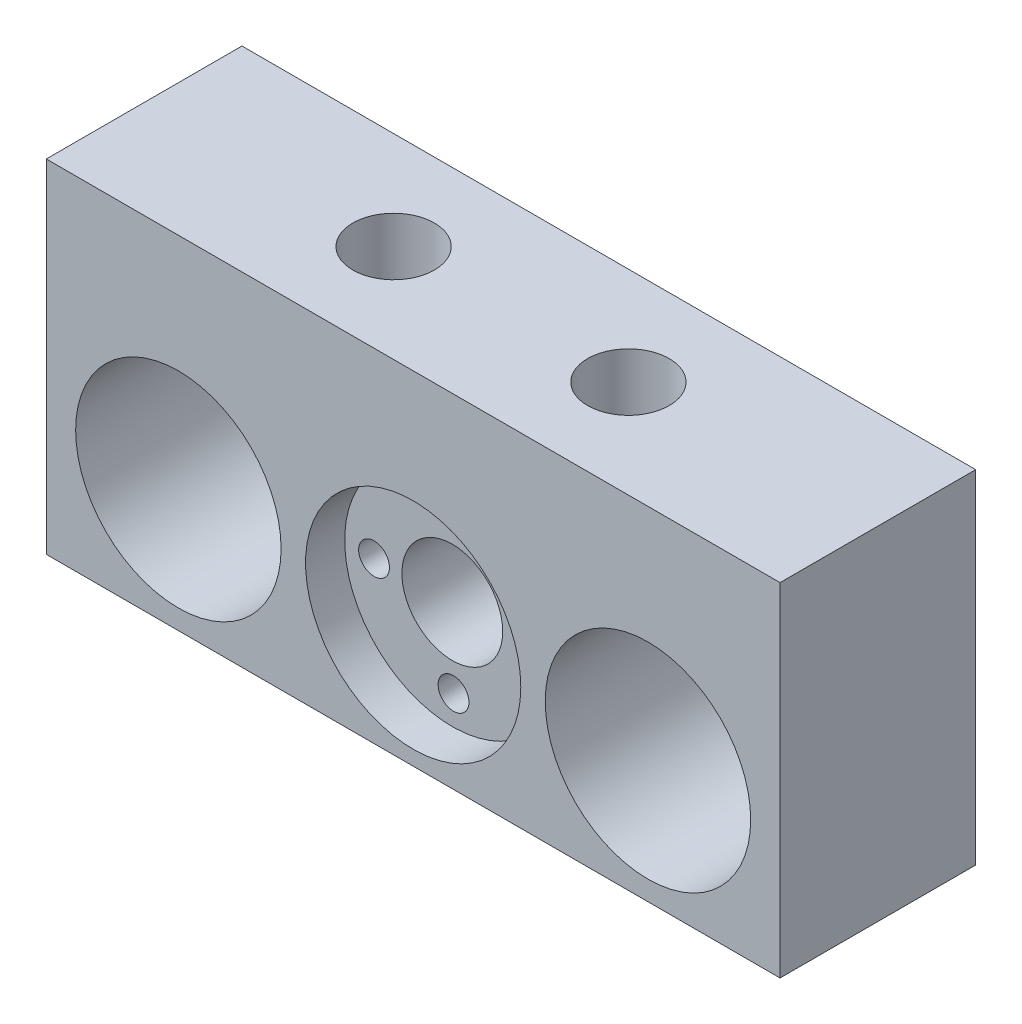
from build123d import *

# Parameters (mm, degrees)
ESBO_O1_W                                    = 75
ESBO_O1_H                                    = 35
RESSALTO_EXTRUS_O1_DEPTH                     = 20
ESBO_O2_R                                    = 10.5
ESBO_O2_R_2                                  = 5.15
CORTE_EXTRUS_O1_DEPTH                        = 21
ESBO_O3_R                                    = 11
CORTE_EXTRUS_O2_DEPTH                        = 4
FURO_ROSCADO_PARA_CONDU_TE_DE_M3X0_51_D      = 3.15
FURO_ROSCADO_PARA_CONDU_TE_DE_M3X0_51_DEPTH  = 10
FURO_ROSCADO_PARA_CONDU_TE_DE_M3X0_51_TIP    = 0.946355475
FURO_ROSCADO_PARA_CONDU_TE_DE_5_16_241_D     = 8.33374
FURO_ROSCADO_PARA_CONDU_TE_DE_5_16_241_DEPTH = 12
FURO_ROSCADO_PARA_CONDU_TE_DE_5_16_241_TIP   = 2.503708088


with BuildPart() as part:
    # Esboço1 → Ressalto-extrusão1 (new body)
    with BuildSketch(Plane.XY):
        Rectangle(ESBO_O1_W, ESBO_O1_H)
    extrude(amount=RESSALTO_EXTRUS_O1_DEPTH)

    # Esboço2 → Corte-extrusão1 (cut, through all)
    with BuildSketch(Plane.XY.offset(20)):
        with Locations((-24, -5)):
            Circle(ESBO_O2_R)
        with Locations((0, -5)):
            Circle(ESBO_O2_R_2)
        with Locations((24, -5)):
            Circle(ESBO_O2_R)
    extrude(amount=-CORTE_EXTRUS_O1_DEPTH, mode=Mode.SUBTRACT)

    # Esboço3 → Corte-extrusão2 (cut)
    with BuildSketch(Plane.XY.offset(20)):
        with Locations((0, -5)):
            Circle(ESBO_O3_R)
    extrude(amount=-CORTE_EXTRUS_O2_DEPTH, mode=Mode.SUBTRACT)

    # Furo roscado para conduíte de M3x0.51
    with Locations(Plane.XY.offset(16)):
        with Locations((-8, -5.125635555), (-0.125635555, 3), (8, -4.874364445), (0.125635555, -13)):
            Hole(FURO_ROSCADO_PARA_CONDU_TE_DE_M3X0_51_D / 2, depth=FURO_ROSCADO_PARA_CONDU_TE_DE_M3X0_51_DEPTH)
            with Locations((0, 0, -(FURO_ROSCADO_PARA_CONDU_TE_DE_M3X0_51_DEPTH + FURO_ROSCADO_PARA_CONDU_TE_DE_M3X0_51_TIP / 2))):  # 118° drill point
                Cone(0, FURO_ROSCADO_PARA_CONDU_TE_DE_M3X0_51_D / 2, FURO_ROSCADO_PARA_CONDU_TE_DE_M3X0_51_TIP, mode=Mode.SUBTRACT)

    # Furo roscado para conduíte de 5/16-241
    with Locations(Plane(origin=(0, 17.5, 0), x_dir=(1, 0, 0), z_dir=(0, 1, 0))):
        with Locations((-12, -10), (12, -10)):
            Hole(FURO_ROSCADO_PARA_CONDU_TE_DE_5_16_241_D / 2, depth=FURO_ROSCADO_PARA_CONDU_TE_DE_5_16_241_DEPTH)
            with Locations((0, 0, -(FURO_ROSCADO_PARA_CONDU_TE_DE_5_16_241_DEPTH + FURO_ROSCADO_PARA_CONDU_TE_DE_5_16_241_TIP / 2))):  # 118° drill point
                Cone(0, FURO_ROSCADO_PARA_CONDU_TE_DE_5_16_241_D / 2, FURO_ROSCADO_PARA_CONDU_TE_DE_5_16_241_TIP, mode=Mode.SUBTRACT)


solid = part.part
